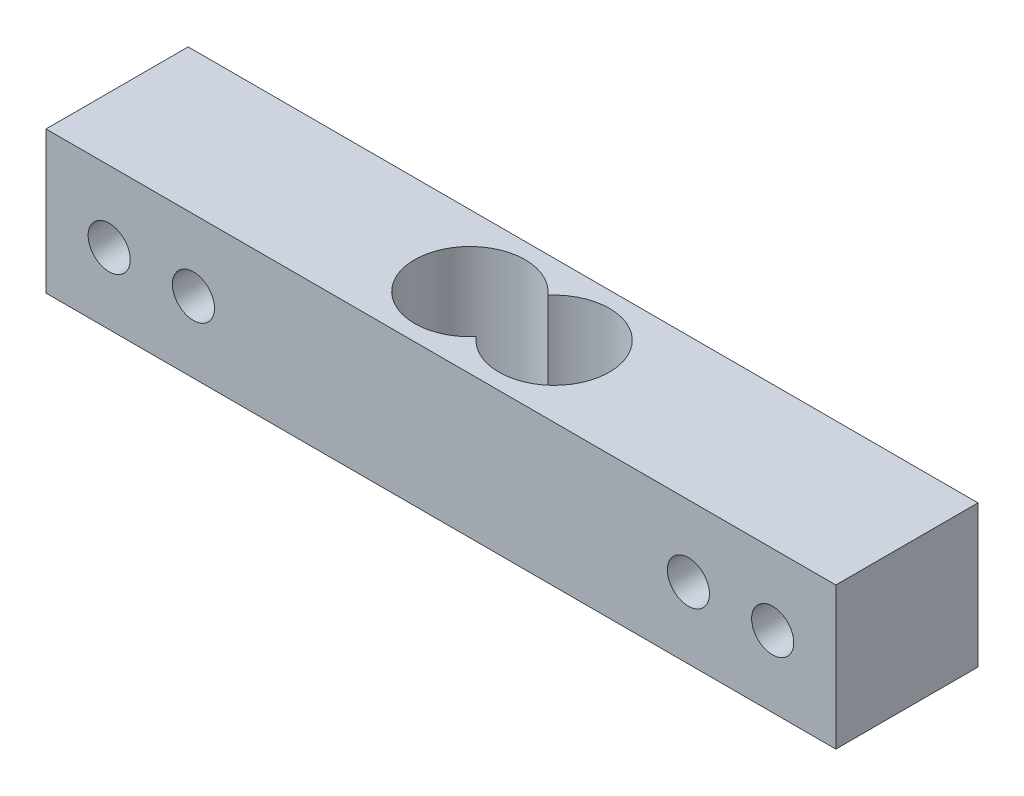
from build123d import *

# Parameters (mm, degrees)
SKETCH2_W           = 75
SKETCH2_H           = 13.5
SKETCH2_R           = 2
BOSS_EXTRUDE1_DEPTH = 13.5
CUT_EXTRUDE1_DEPTH  = 13.5


with BuildPart() as part:
    # Sketch2 → Boss-Extrude1 (new body)
    with BuildSketch(Plane.XY):
        with Locations((37.5, 6.75)):
            Rectangle(SKETCH2_W, SKETCH2_H)
        with Locations((6, 6.75)):
            Circle(SKETCH2_R, mode=Mode.SUBTRACT)
        with Locations((14, 6.75)):
            Circle(SKETCH2_R, mode=Mode.SUBTRACT)
        with Locations((69, 6.75)):
            Circle(SKETCH2_R, mode=Mode.SUBTRACT)
        with Locations((61, 6.75)):
            Circle(SKETCH2_R, mode=Mode.SUBTRACT)
    extrude(amount=BOSS_EXTRUDE1_DEPTH)

    # Sketch3 → Cut-Extrude1 (cut)
    with BuildSketch(Plane(origin=(0, 13.5, 0), x_dir=(1, 0, 0), z_dir=(0, 1, 0))):
        with BuildLine():
            ThreePointArc((37.5, -3.349632373), (28.25, -6.75), (37.5, -10.150367627))
            ThreePointArc((37.5, -10.150367627), (46.75, -6.75), (37.5, -3.349632373))
        make_face()
    extrude(amount=-CUT_EXTRUDE1_DEPTH, mode=Mode.SUBTRACT)


solid = part.part
